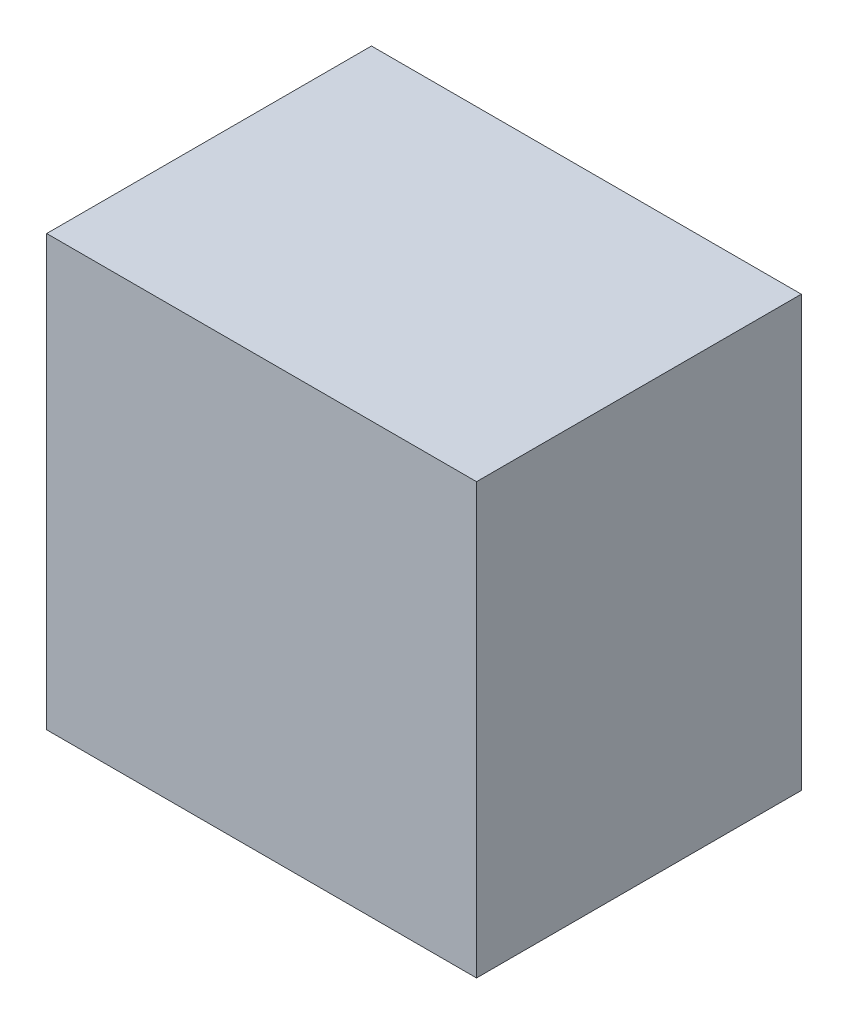
from build123d import *

# Parameters (mm, degrees)
SKETCH1_W           = 180
SKETCH1_H           = 180
BOSS_EXTRUDE1_DEPTH = 68


with BuildPart() as part:
    # Sketch1 → Boss-Extrude1 (new body, symmetric)
    with BuildSketch(Plane.XY):
        Rectangle(SKETCH1_W, SKETCH1_H)
    extrude(amount=BOSS_EXTRUDE1_DEPTH, both=True)


solid = part.part
